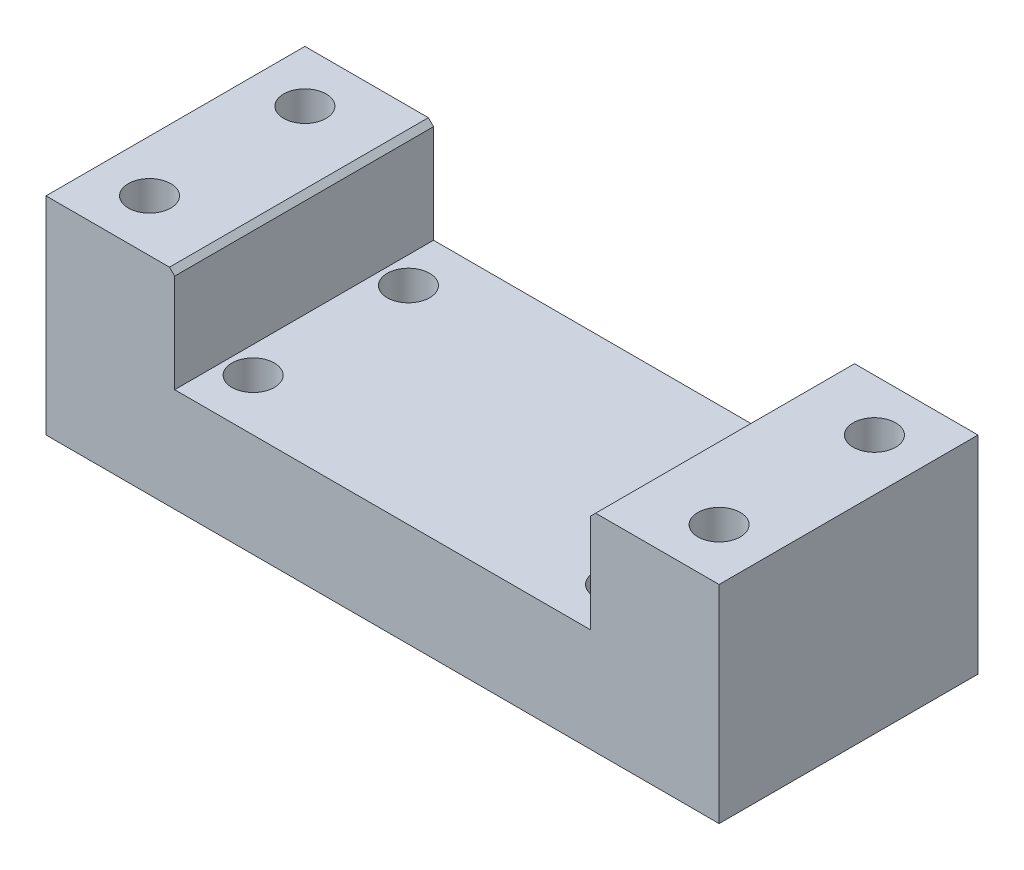
from build123d import *

# Parameters (mm, degrees)
SKETCH1_W           = 130
SKETCH1_H           = 50
BOSS_EXTRUDE1_DEPTH = 40
SKETCH2_W           = 80.3
SKETCH2_H           = 40
CUT_EXTRUDE1_DEPTH  = 51
SKETCH3_R           = 4.1
CUT_EXTRUDE2_DEPTH  = 41
CHAMFER1_SIZE       = 1
SKETCH5_R           = 4.1
CUT_EXTRUDE3_DEPTH  = 41


with BuildPart() as part:
    # Sketch1 → Boss-Extrude1 (new body)
    with BuildSketch(Plane(origin=(0, 0, 0), x_dir=(1, 0, 0), z_dir=(0, 1, 0))):
        Rectangle(SKETCH1_W, SKETCH1_H)
    extrude(amount=BOSS_EXTRUDE1_DEPTH)

    # Sketch2 → Cut-Extrude1 (cut, through all)
    with BuildSketch(Plane.XY.offset(25)):
        with Locations((0, 40)):
            Rectangle(SKETCH2_W, SKETCH2_H)
    extrude(amount=-CUT_EXTRUDE1_DEPTH, mode=Mode.SUBTRACT)

    # Sketch3 → Cut-Extrude2 (cut, through all)
    with BuildSketch(Plane.XZ):
        with Locations((-35, 15)):
            Circle(SKETCH3_R)
        with Locations((-35, -15)):
            Circle(SKETCH3_R)
        with Locations((35, -14.217273236)):
            Circle(SKETCH3_R)
        with Locations((35, 15)):
            Circle(SKETCH3_R)
    extrude(amount=-CUT_EXTRUDE2_DEPTH, mode=Mode.SUBTRACT)

    # Chamfer1
    chamfer1_edges = [part.edges().sort_by_distance(p)[0] for p in [
        (40.15, 40, 0),
        (-40.15, 40, 0),
    ]]
    chamfer(chamfer1_edges, length=CHAMFER1_SIZE)

    # Sketch5 → Cut-Extrude3 (cut, through all)
    with BuildSketch(Plane.XZ):
        with Locations((-55, 15)):
            Circle(SKETCH5_R)
        with Locations((-55, -15)):
            Circle(SKETCH5_R)
        with Locations((55, 15)):
            Circle(SKETCH5_R)
        with Locations((55, -15)):
            Circle(SKETCH5_R)
    extrude(amount=-CUT_EXTRUDE3_DEPTH, mode=Mode.SUBTRACT)


solid = part.part
